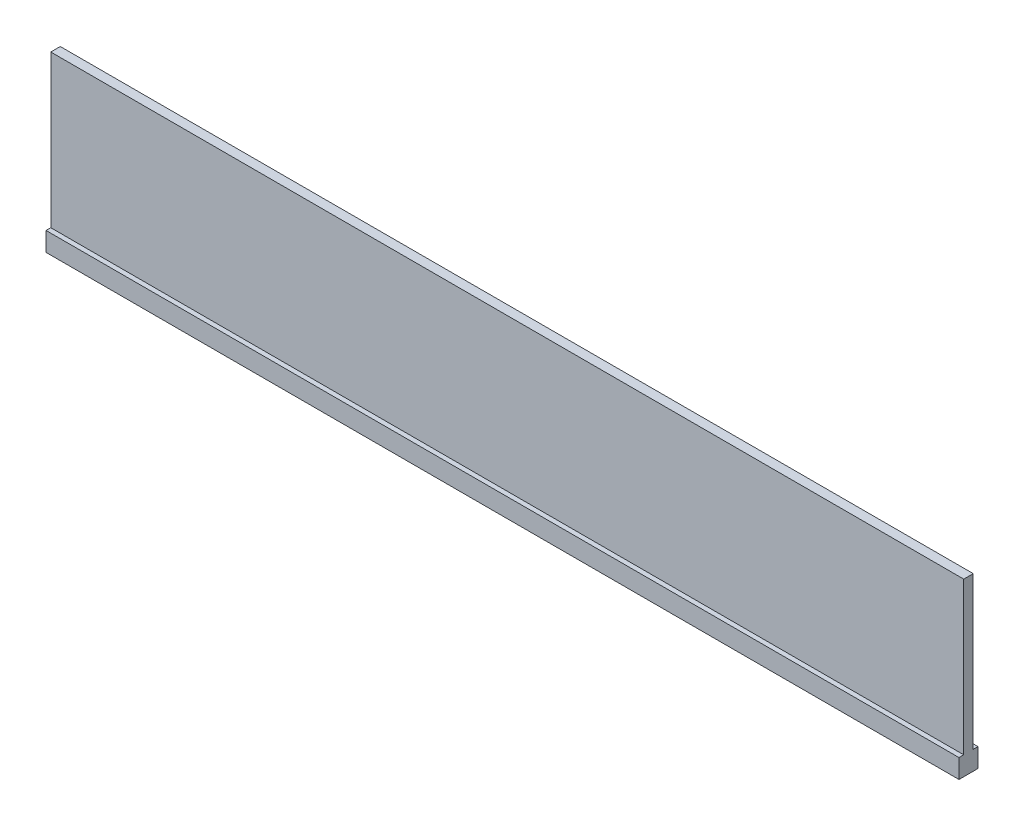
from build123d import *

# Parameters (mm, degrees)
SKETCH1_W           = 152.4
SKETCH1_H           = 25.4
BOSS_EXTRUDE1_DEPTH = 1.5875
SKETCH2_W           = 3.175
SKETCH2_H           = 3.175
BOSS_EXTRUDE2_DEPTH = 152.4


with BuildPart() as part:
    # Sketch1 → Boss-Extrude1 (new body)
    with BuildSketch(Plane.XY):
        with Locations((-15.173816053, 41.697804783)):
            Rectangle(SKETCH1_W, SKETCH1_H)
    extrude(amount=BOSS_EXTRUDE1_DEPTH)

    # Sketch2 → Boss-Extrude2 (add)
    with BuildSketch(Plane.ZY.offset(91.373816053)):
        with Locations((0.79375, 27.410304783)):
            Rectangle(SKETCH2_W, SKETCH2_H)
    extrude(amount=-BOSS_EXTRUDE2_DEPTH)


solid = part.part
